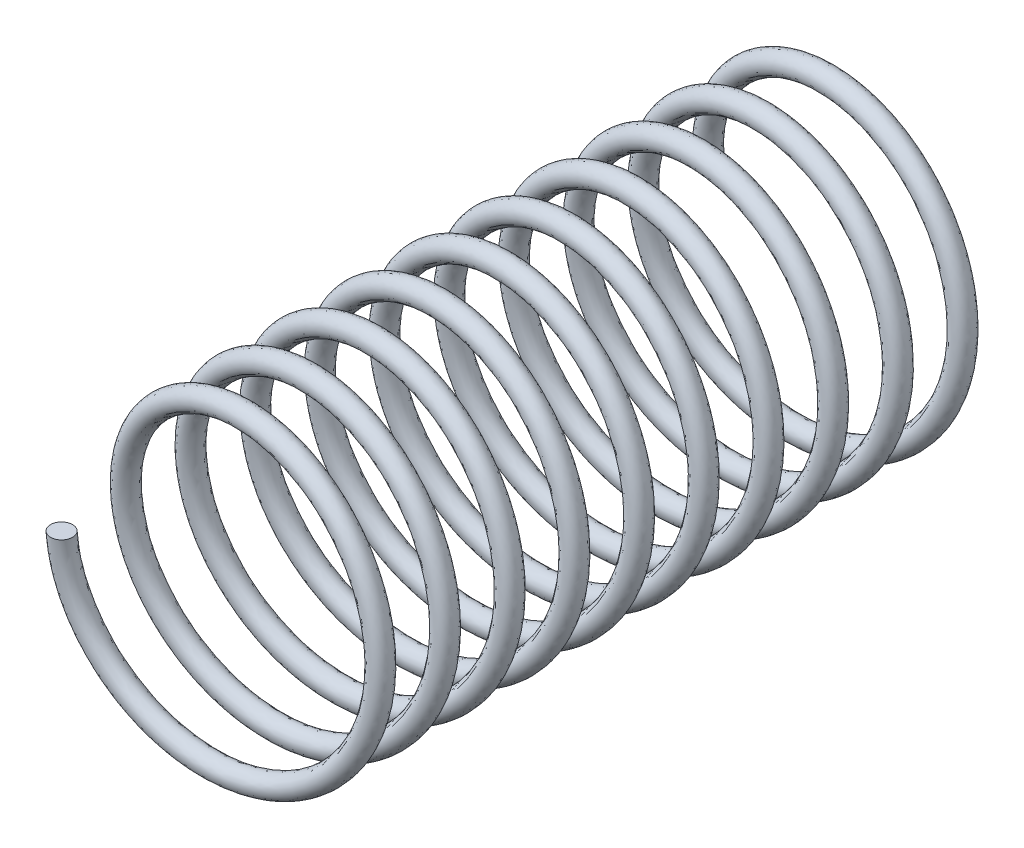
from build123d import *

# Parameters (mm, degrees)
SWEEP1_PITCH       = 5.88
SWEEP1_HEIGHT      = 58.8
SWEEP1_RADIUS      = 13
SWEEP1_START_ANGLE = -180
SKETCH4_R          = 1


with BuildPart() as part:
    # Sweep1: sweep along a helix
    with BuildLine() as sweep1_path:
        add(Helix(SWEEP1_PITCH, SWEEP1_HEIGHT, SWEEP1_RADIUS, center=(13, 0, 0), direction=(0, 0, 1), lefthand=True, mode=Mode.PRIVATE).rotate(Axis((13, 0, 0), (0, 0, 1)), SWEEP1_START_ANGLE))
    # Sketch4 → Sweep1 (sweep)
    with BuildSketch(Plane(origin=(0, 0, 0), x_dir=(1, 0, 0), z_dir=(0, 1, 0))):
        Circle(SKETCH4_R)
    sweep(path=sweep1_path.line, is_frenet=True)


solid = part.part
